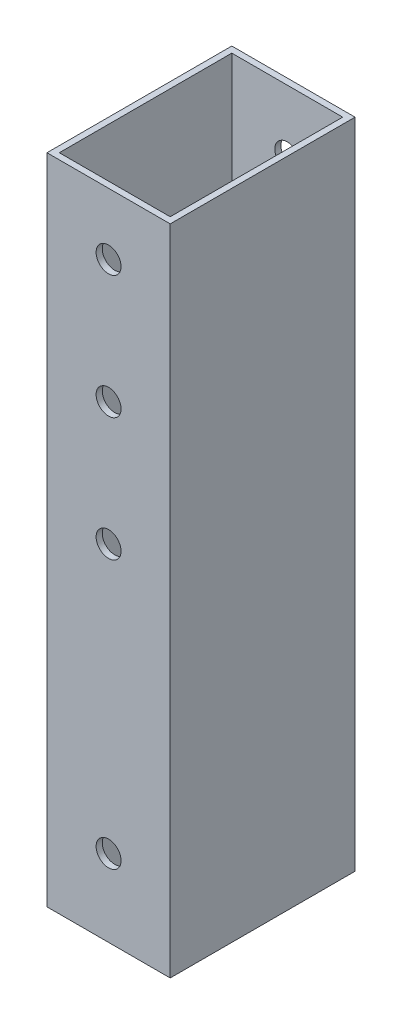
from build123d import *

# Parameters (mm, degrees)
SKETCH_2_W               = 20
SKETCH_2_H               = 30
EXTRUDE_1_DEPTH          = 60
SKETCH_3_W               = 18
SKETCH_3_H               = 28
CUT_EXTRUDE_1_DEPTH      = 61
CUT_EXTRUDE_1_DEPTH_BACK = 61
SKETCH_5_W               = 20
SKETCH_5_H               = 14
CUT_EXTRUDE_3_DEPTH      = 1
CUT_EXTRUDE_3_DEPTH_BACK = 31
SKETCH_6_R               = 2.025
CUT_EXTRUDE_4_DEPTH      = 31
SKETCH_7_R               = 2.025
CUT_EXTRUDE_5_DEPTH      = 1
CUT_EXTRUDE_5_DEPTH_BACK = 31


with BuildPart() as part:
    # 草图2 → 凸台-拉伸1 (new body, symmetric)
    with BuildSketch(Plane(origin=(0, 0, 0), x_dir=(1, 0, 0), z_dir=(0, 1, 0))):
        Rectangle(SKETCH_2_W, SKETCH_2_H)
    extrude(amount=EXTRUDE_1_DEPTH, both=True)

    # 草图3 → 切除-拉伸1 (cut, two sides)
    with BuildSketch(Plane(origin=(0, 0, 0), x_dir=(1, 0, 0), z_dir=(0, 1, 0))) as cut_extrude_1_sk:
        Rectangle(SKETCH_3_W, SKETCH_3_H)
    extrude(amount=CUT_EXTRUDE_1_DEPTH, mode=Mode.SUBTRACT)
    extrude(cut_extrude_1_sk.sketch, amount=-CUT_EXTRUDE_1_DEPTH_BACK, mode=Mode.SUBTRACT)

    # 草图5 → 切除-拉伸3 (cut, two sides)
    with BuildSketch(Plane.XY.offset(15)) as cut_extrude_3_sk:
        with Locations((0, -53)):
            Rectangle(SKETCH_5_W, SKETCH_5_H)
    extrude(amount=CUT_EXTRUDE_3_DEPTH, mode=Mode.SUBTRACT)
    extrude(cut_extrude_3_sk.sketch, amount=-CUT_EXTRUDE_3_DEPTH_BACK, mode=Mode.SUBTRACT)

    # 草图6 → 切除-拉伸4 (cut, through all)
    with BuildSketch(Plane.XY.offset(15)):
        with Locations((0, -33.5)):
            Circle(SKETCH_6_R)
    extrude(amount=-CUT_EXTRUDE_4_DEPTH, mode=Mode.SUBTRACT)

    # 草图7 → 切除-拉伸5 (cut, two sides)
    with BuildSketch(Plane.XY.offset(15)) as cut_extrude_5_sk:
        with Locations((0, 50)):
            Circle(SKETCH_7_R)
        with Locations((0, 30)):
            Circle(SKETCH_7_R)
        with Locations((0, 10)):
            Circle(SKETCH_7_R)
    extrude(amount=CUT_EXTRUDE_5_DEPTH, mode=Mode.SUBTRACT)
    extrude(cut_extrude_5_sk.sketch, amount=-CUT_EXTRUDE_5_DEPTH_BACK, mode=Mode.SUBTRACT)


solid = part.part
